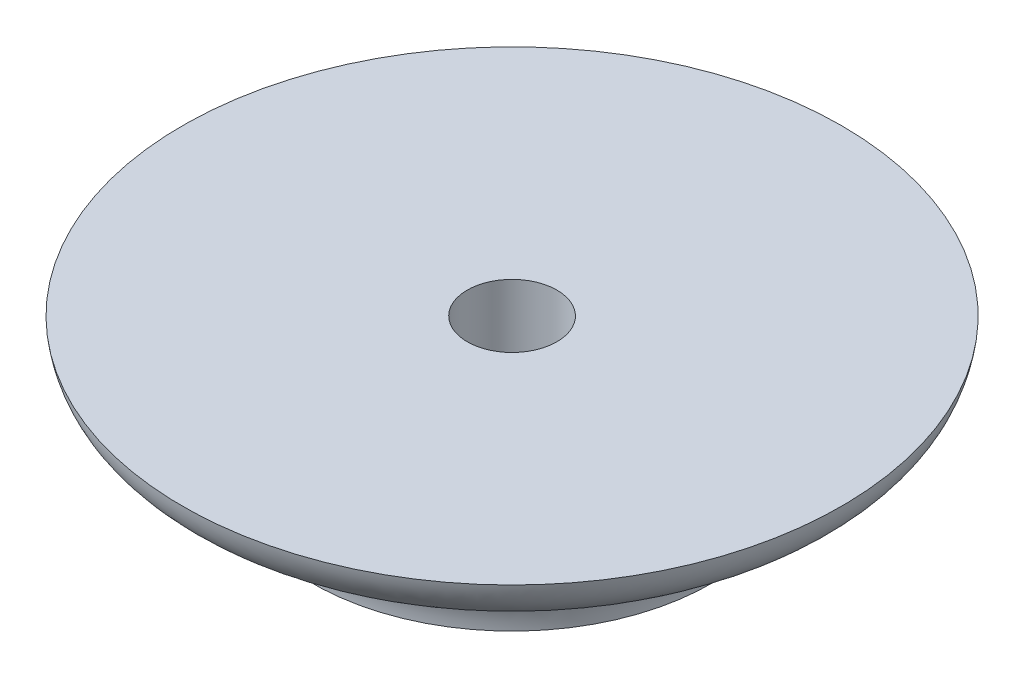
from build123d import *

# Parameters (mm, degrees)
SKETCH1_R             = 12.7
BOSS_EXTRUDE1_DEPTH   = 5.08
F_8_32_TAPPED_HOLE1_D = 3.4544


with BuildPart() as part:
    # Sketch1 → Boss-Extrude1 (new body)
    with BuildSketch(Plane(origin=(0, 0, 0), x_dir=(1, 0, 0), z_dir=(0, 1, 0))):
        Circle(SKETCH1_R)
    extrude(amount=BOSS_EXTRUDE1_DEPTH)

    # Sketch2 → Cut-Revolve1 (revolve, cut)
    with BuildSketch(Plane(origin=(0, 0, 0), x_dir=(0, 0, -1), z_dir=(1, 0, 0))):
        with BuildLine():
            add(Edge.make_bspline(
                [(-12.7, 5.08), (-12.29250781, 2.070805796), (-7.694111536, 3.636711405), (-7.694111536, 0)],
                knots=[0, 0, 0, 0, 1, 1, 1, 1], degree=3))
            Line((-12.7, 5.08), (-12.7, 0))
            Line((-12.7, 0), (-7.694111536, 0))
        make_face()
    revolve(axis=Axis((0, 0, 0), (0, 1, 0)), mode=Mode.SUBTRACT)

    # #8-32 Tapped Hole1 (through all)
    with Locations(Plane(origin=(0, 0, 0), x_dir=(-1, 0, 0), z_dir=(0, -1, 0))):
        with Locations((0, 0)):
            Hole(F_8_32_TAPPED_HOLE1_D / 2)


solid = part.part
